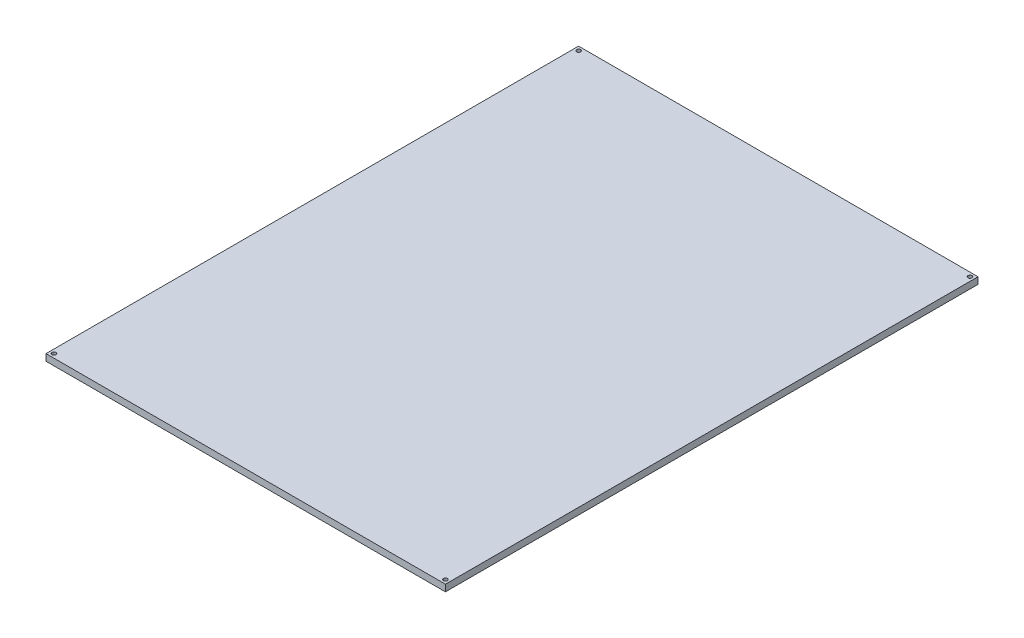
from build123d import *

# Parameters (mm, degrees)
SKETCH_1_W          = 300
SKETCH_1_H          = 400
EXTRUDE_1_DEPTH     = 5
SKETCH_2_R          = 1.5
CUT_EXTRUDE_1_DEPTH = 5


with BuildPart() as part:
    # Эскиз1 → Бобышка-Вытянуть1 (new body)
    with BuildSketch(Plane(origin=(0, 0, 0), x_dir=(1, 0, 0), z_dir=(0, 1, 0))):
        Rectangle(SKETCH_1_W, SKETCH_1_H)
    extrude(amount=EXTRUDE_1_DEPTH)

    # Эскиз2 → Вырез-Вытянуть1 (cut)
    with BuildSketch(Plane(origin=(0, 5, 0), x_dir=(1, 0, 0), z_dir=(0, 1, 0))):
        with Locations((-147, 197)):
            Circle(SKETCH_2_R)
        with Locations((147, 197)):
            Circle(SKETCH_2_R)
        with Locations((147, -197)):
            Circle(SKETCH_2_R)
        with Locations((-147, -197)):
            Circle(SKETCH_2_R)
    extrude(amount=-CUT_EXTRUDE_1_DEPTH, mode=Mode.SUBTRACT)


solid = part.part
